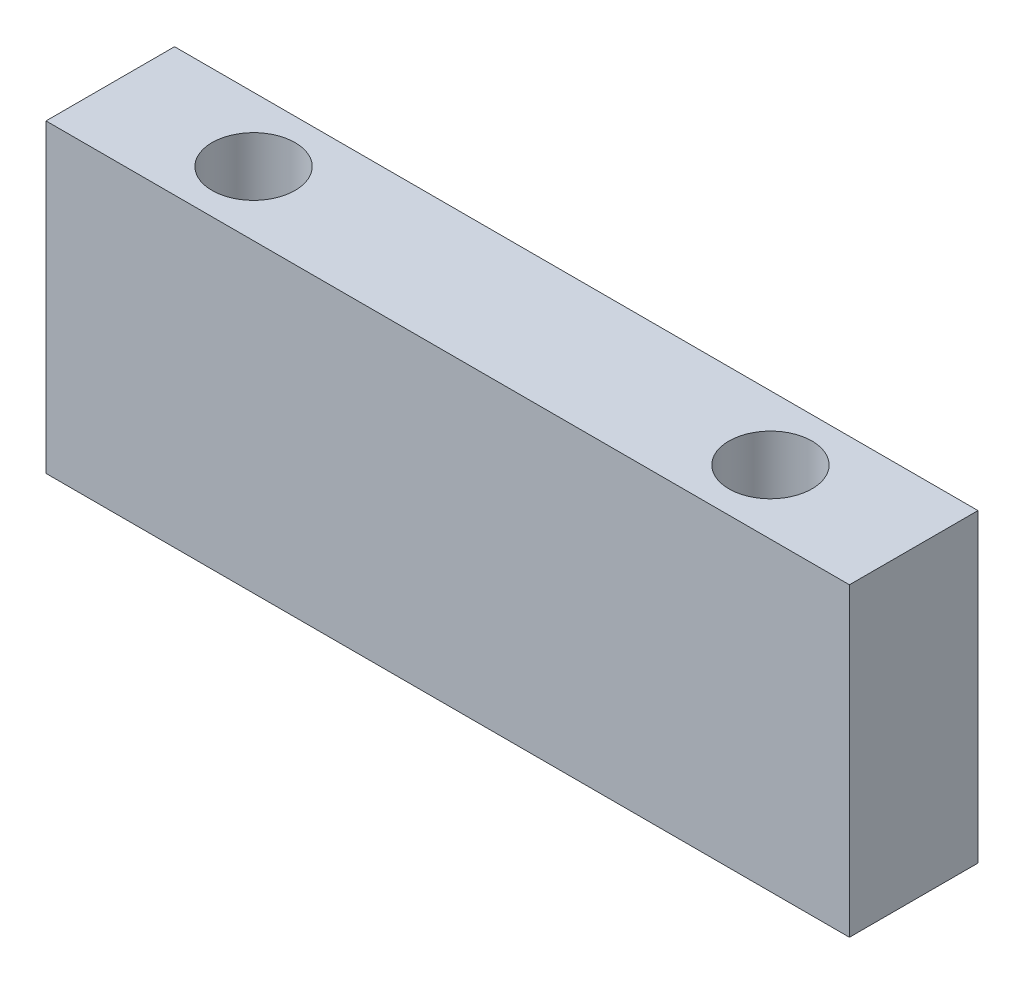
from build123d import *

# Parameters (mm, degrees)
SKETCH1_W           = 76.2
SKETCH1_H           = 28.956
BOSS_EXTRUDE1_DEPTH = 12.192
SKETCH2_R           = 3.937
CUT_EXTRUDE1_DEPTH  = 29.956


with BuildPart() as part:
    # Sketch1 → Boss-Extrude1 (new body)
    with BuildSketch(Plane.XY):
        with Locations((38.1, 14.478)):
            Rectangle(SKETCH1_W, SKETCH1_H)
    extrude(amount=BOSS_EXTRUDE1_DEPTH)

    # Sketch2 → Cut-Extrude1 (cut, through all)
    with BuildSketch(Plane(origin=(0, 28.956, 0), x_dir=(1, 0, 0), z_dir=(0, 1, 0))):
        with Locations(Location((62.611, -6.096, 0), (0, 0, 180))):  # turned: the seam where the file's is
            Circle(SKETCH2_R)
        with Locations(Location((13.589, -6.096, 0), (0, 0, 180))):  # turned: the seam where the file's is
            Circle(SKETCH2_R)
    extrude(amount=-CUT_EXTRUDE1_DEPTH, mode=Mode.SUBTRACT)


solid = part.part
